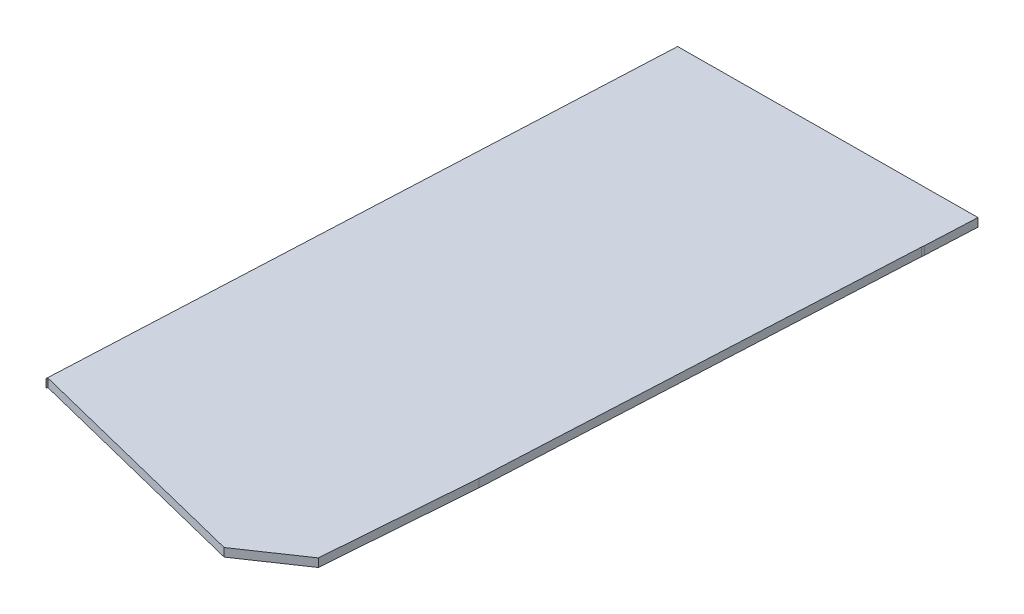
from build123d import *

# Parameters (mm, degrees)
BOSS_EXTRU_1_DEPTH = 2


with BuildPart() as part:
    # Esquisse1 → Boss.-Extru.1 (new body)
    with BuildSketch(Plane(origin=(0, 0, 0), x_dir=(1, 0, 0), z_dir=(0, 1, 0))):
        Polygon((6.791328515, 145.065600746), (0, 0), (0.107140545, 0.348396823), (56.602007535, -13.760167019), (70.071492633, -4.602313851), (72.817368262, 31.319723445), (77.869507186, 132.676717249), (77.934833377, 133.237659453), (78.512273118, 145.572012404), align=None)
    extrude(amount=BOSS_EXTRU_1_DEPTH)


solid = part.part
